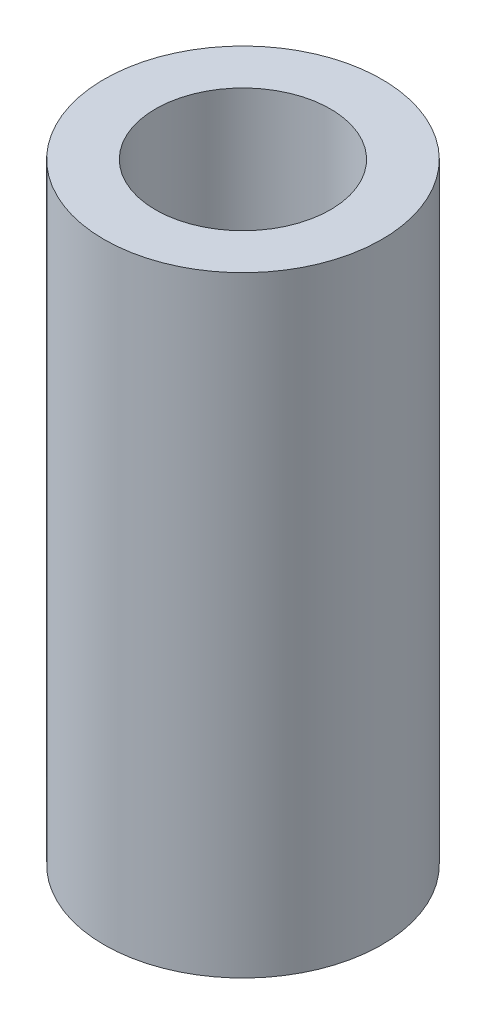
from build123d import *

# Parameters (mm, degrees)
SKETCH1_R           = 3.175
SKETCH1_R_2         = 1.999996
BOSS_EXTRUDE1_DEPTH = 13.97


with BuildPart() as part:
    # Sketch1 → Boss-Extrude1 (new body)
    with BuildSketch(Plane(origin=(0, 0, 0), x_dir=(1, 0, 0), z_dir=(0, 1, 0))):
        Circle(SKETCH1_R)
        Circle(SKETCH1_R_2, mode=Mode.SUBTRACT)
    extrude(amount=-BOSS_EXTRUDE1_DEPTH)


solid = part.part
